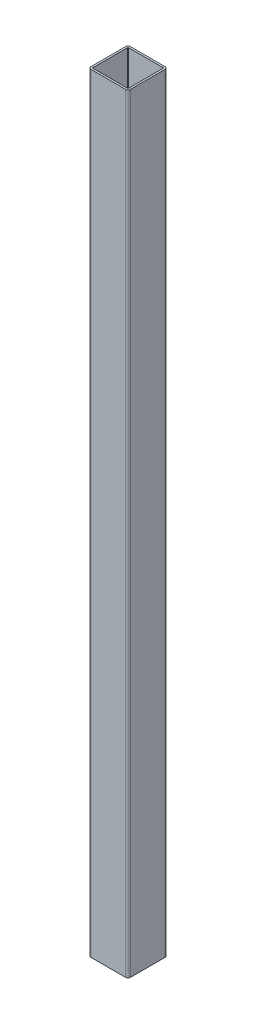
from build123d import *

# Parameters (mm, degrees)
BOSS_EXTRUDE1_DEPTH = 650
SCALE1_SCALE        = 7.5


with BuildPart() as part:
    # Sketch1 → Boss-Extrude1 (new body)
    with BuildSketch(Plane(origin=(0, 0, 0), x_dir=(1, 0, 0), z_dir=(0, 1, 0))):
        with BuildLine():
            Line((2, 0), (31.333333333, 0))
            ThreePointArc((31.333333333, 0), (32.747546896, 0.585786438), (33.333333333, 2))
            Line((33.333333333, 2), (33.333333333, 31.333333333))
            ThreePointArc((33.333333333, 31.333333333), (32.747546896, 32.747546896), (31.333333333, 33.333333333))
            Line((31.333333333, 33.333333333), (2, 33.333333333))
            ThreePointArc((2, 33.333333333), (0.585786438, 32.747546896), (0, 31.333333333))
            Line((0, 31.333333333), (0, 2))
            ThreePointArc((0, 2), (0.585786438, 0.585786438), (2, 0))
        make_face()
        with BuildLine():
            Line((1.6, 2), (1.6, 31.333333333))
            ThreePointArc((1.6, 31.333333333), (1.717157288, 31.616176046), (2, 31.733333333))
            Line((2, 31.733333333), (31.333333333, 31.733333333))
            ThreePointArc((31.333333333, 31.733333333), (31.616176046, 31.616176046), (31.733333333, 31.333333333))
            Line((31.733333333, 31.333333333), (31.733333333, 2))
            ThreePointArc((31.733333333, 2), (31.616176046, 1.717157288), (31.333333333, 1.6))
            Line((31.333333333, 1.6), (2, 1.6))
            ThreePointArc((2, 1.6), (1.717157288, 1.717157288), (1.6, 2))
        make_face(mode=Mode.SUBTRACT)
    extrude(amount=BOSS_EXTRUDE1_DEPTH)


with BuildPart() as part_1:
    # Scale1: scaled about (16.666666667, 325, -16.666666667)
    add(part.part.scale(SCALE1_SCALE).moved(Location((-108.333333336, -2112.5, 108.333333336))))


solid = part_1.part
